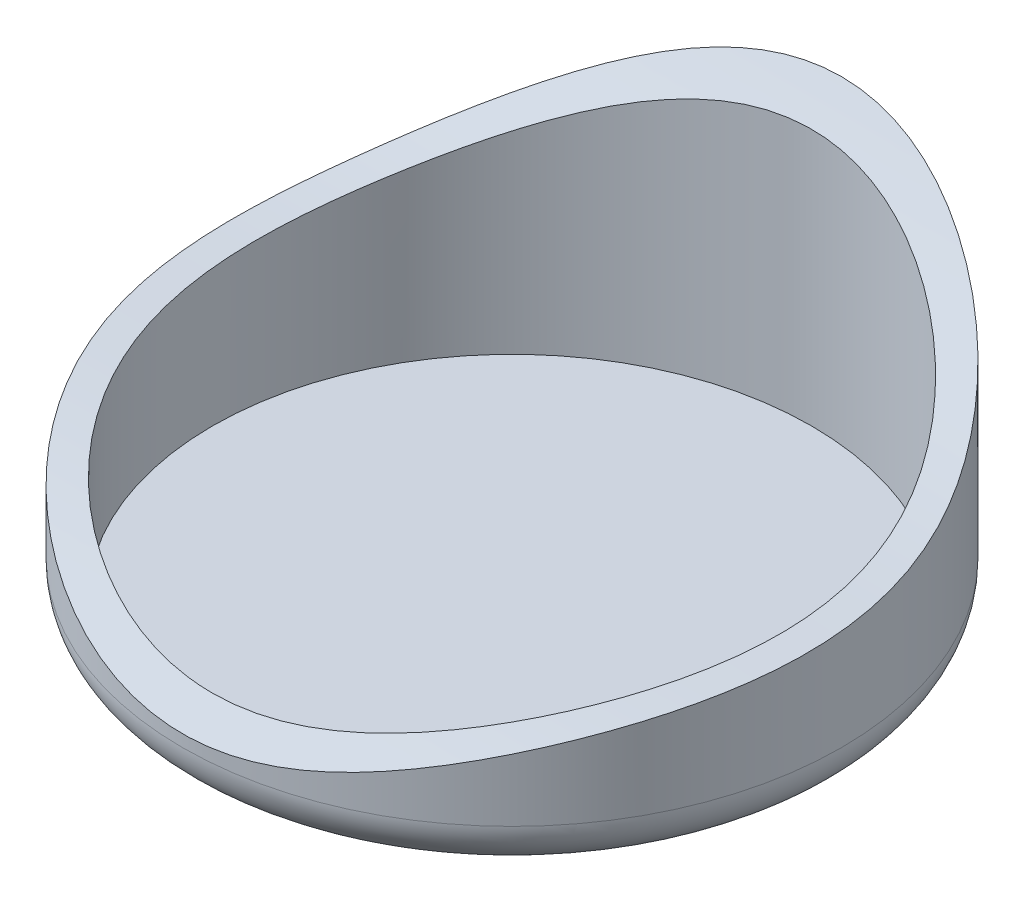
from build123d import *

# Parameters (mm, degrees)
SKETCH1_R           = 55
BOSS_EXTRUDE1_DEPTH = 50
SKETCH2_R           = 50
CUT_EXTRUDE1_DEPTH  = 48
CUT_EXTRUDE2_DEPTH  = 64
SKETCH4_R           = 45
BOSS_EXTRUDE2_DEPTH = 2
FILLET1_R           = 8


with BuildPart() as part:
    # Sketch1 → Boss-Extrude1 (new body)
    with BuildSketch(Plane(origin=(0, 0, 0), x_dir=(1, 0, 0), z_dir=(0, 1, 0))):
        Circle(SKETCH1_R)
    extrude(amount=BOSS_EXTRUDE1_DEPTH)

    # Sketch2 → Cut-Extrude1 (cut)
    with BuildSketch(Plane(origin=(0, 50, 0), x_dir=(1, 0, 0), z_dir=(0, 1, 0))):
        Circle(SKETCH2_R)
    extrude(amount=-CUT_EXTRUDE1_DEPTH, mode=Mode.SUBTRACT)

    # Sketch3 → Cut-Extrude2 (cut, symmetric)
    with BuildSketch(Plane(origin=(0, 0, 0), x_dir=(0, 0, -1), z_dir=(1, 0, 0))):
        with BuildLine():
            Line((-55, 10), (-55, 50))
            Line((-55, 50), (55, 50))
            add(Edge.make_bspline(
                [(-55, 10), (-32.185575053, 27.405291441), (13.190680472, 18.202995652), (46.289902957, 40.289555955), (55, 50)],
                knots=[0, 0, 0, 0, 0.690633178, 1, 1, 1, 1], degree=3))
        make_face()
    extrude(amount=CUT_EXTRUDE2_DEPTH, both=True, mode=Mode.SUBTRACT)

    # Sketch4 → Boss-Extrude2 (add)
    with BuildSketch(Plane.XZ):
        Circle(SKETCH4_R)
    extrude(amount=BOSS_EXTRUDE2_DEPTH)

    # Fillet1
    fillet1_edges = [part.edges().sort_by_distance(p)[0] for p in [
        (-55, 0, 0),
    ]]
    fillet(fillet1_edges, radius=FILLET1_R)


solid = part.part
